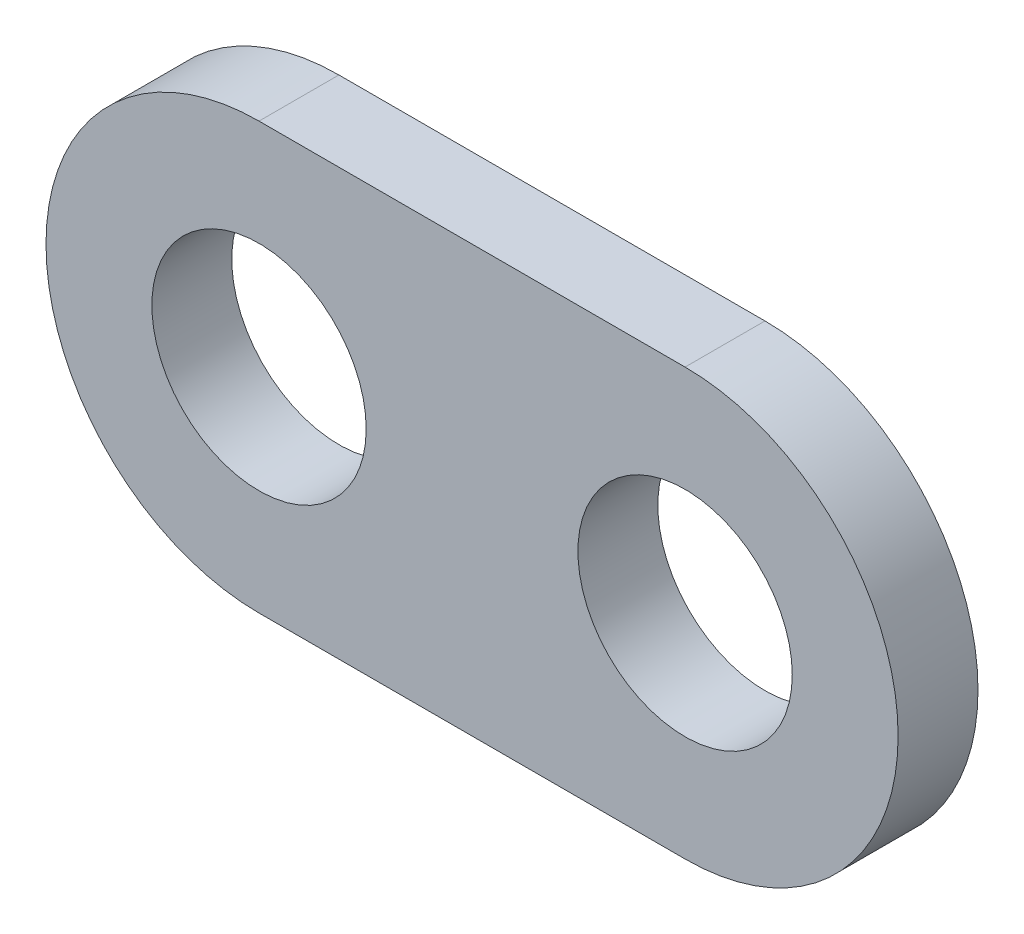
from build123d import *

# Parameters (mm, degrees)
EXTRUDE_START   = 6
SKETCH_1_R      = 4.025
EXTRUDE_1_DEPTH = 3


with BuildPart() as part:
    # ｽｹｯﾁ1 → ﾎﾞｽ - 押し出し1 (new body)
    with BuildSketch(Plane.XY.offset(EXTRUDE_START)):
        with BuildLine():
            ThreePointArc((8, 54), (0, 46), (8, 38))
            Line((8, 38), (24, 38))
            ThreePointArc((24, 38), (32, 46), (24, 54))
            Line((24, 54), (8, 54))
        make_face()
        with Locations((8, 46)):
            Circle(SKETCH_1_R, mode=Mode.SUBTRACT)
        with Locations((24, 46)):
            Circle(SKETCH_1_R, mode=Mode.SUBTRACT)
    extrude(amount=EXTRUDE_1_DEPTH)


solid = part.part
